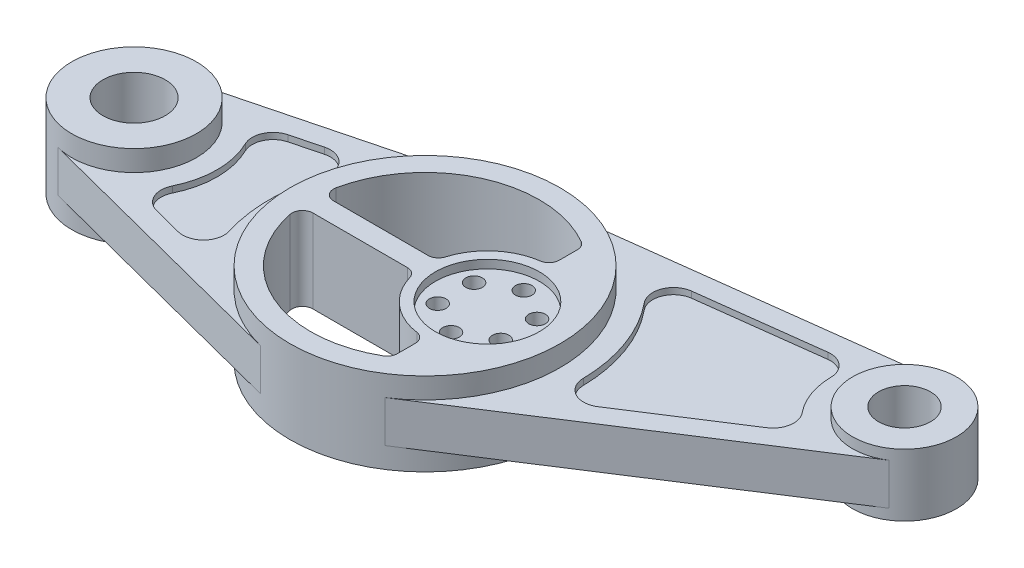
from build123d import *

# Parameters (mm, degrees)
BOSS_EXTRUDE1_DEPTH  = 10
SKETCH2_R            = 65
BOSS_EXTRUDE2_DEPTH  = 20
SKETCH3_R            = 30
BOSS_EXTRUDE3_DEPTH  = 20
SKETCH5_R            = 25
BOSS_EXTRUDE4_DEPTH  = 15
CUT_EXTRUDE1_DEPTH   = 41
SKETCH8_R            = 25
CUT_EXTRUDE3_DEPTH   = 4
SKETCH9_R            = 4
CUT_EXTRUDE4_DEPTH   = 37
CIRPATTERN1_COUNT    = 6
SKETCH10_R           = 15
CUT_EXTRUDE5_DEPTH   = 41
SKETCH11_R           = 12.5
CUT_EXTRUDE6_DEPTH   = 36
CUT_EXTRUDE7_DEPTH   = 3
FILLET1_R            = 10
FILLET1_OF_MIRROR3_R = 10


with BuildPart() as part:
    # Sketch1 → Boss-Extrude1 (new body, symmetric)
    with BuildSketch(Plane(origin=(0, 0, 0), x_dir=(1, 0, 0), z_dir=(0, 1, 0))):
        with BuildLine():
            Line((-147.5, 29.047375), (-16.25, 62.935979))
            ThreePointArc((-16.25, 62.935979), (-12.200915, 63.844637), (-8.102101, 64.493069))
            Line((-8.102101, 64.493069), (166.028479, 86.368652))
            ThreePointArc((166.028479, 86.368652), (192.636987, 70.114129), (182.701893, 40.558823))
            Line((182.701893, 40.558823), (35.248776, -54.612487))
            ThreePointArc((35.248776, -54.612487), (10.371042, -64.167293), (-16.25, -62.935979))
            Line((-16.25, -62.935979), (-147.5, -29.047375))
            ThreePointArc((-147.5, -29.047375), (-170, 0), (-147.5, 29.047375))
        make_face()
    extrude(amount=BOSS_EXTRUDE1_DEPTH, both=True)

    # Sketch2 → Boss-Extrude2 (add, symmetric)
    with BuildSketch(Plane(origin=(0, 0, 0), x_dir=(1, 0, 0), z_dir=(0, 1, 0))):
        with Locations(Location((0, 0, 0), (0, 0, 270))):  # turned: the seam where the file's is
            Circle(SKETCH2_R)
    extrude(amount=BOSS_EXTRUDE2_DEPTH, both=True)

    # Sketch3 → Boss-Extrude3 (add, symmetric)
    with BuildSketch(Plane(origin=(0, 0, 0), x_dir=(1, 0, 0), z_dir=(0, 1, 0))):
        with Locations(Location((-140, 0, 0), (0, 0, 270))):  # turned: the seam where the file's is
            Circle(SKETCH3_R)
    extrude(amount=BOSS_EXTRUDE3_DEPTH, both=True)

    # Sketch5 → Boss-Extrude4 (add, symmetric)
    with BuildSketch(Plane(origin=(0, 0, 0), x_dir=(1, 0, 0), z_dir=(0, 1, 0))):
        with Locations(Location((169.144672, 61.563626, 0), (0, 0, 270))):  # turned: the seam where the file's is
            Circle(SKETCH5_R)
    extrude(amount=BOSS_EXTRUDE4_DEPTH, both=True)

    # Sketch6 → Cut-Extrude1 (cut, through all)
    with BuildSketch(Plane(origin=(0, 20, 0), x_dir=(1, 0, 0), z_dir=(0, 1, 0))):
        with BuildLine():
            Line((-48.989795, 5), (-3.54102, 5))
            ThreePointArc((-3.54102, 5), (-0.552948, 5.991081), (1.250555, 8.571429))
            ThreePointArc((1.250555, 8.571429), (10.395071, 22.707857), (25.714286, 29.6923))
            ThreePointArc((25.714286, 29.6923), (28.779645, 31.367748), (30, 34.641016))
            Line((30, 34.641016), (30, 43.30127))
            ThreePointArc((30, 43.30127), (29.330127, 45.80127), (27.5, 47.631397))
            ThreePointArc((27.5, 47.631397), (-22.573362, 50.154196), (-53.888774, 11))
            ThreePointArc((-53.888774, 11), (-52.862778, 6.837722), (-48.989795, 5))
        make_face()
    cut_extrude1 = extrude(amount=-CUT_EXTRUDE1_DEPTH, mode=Mode.SUBTRACT)

    # Mirror1: Cut-Extrude1 across plane
    add(cut_extrude1.mirror(Plane.XY), mode=Mode.SUBTRACT)

    # Sketch8 → Cut-Extrude3 (cut)
    with BuildSketch(Plane(origin=(0, 20, 0), x_dir=(1, 0, 0), z_dir=(0, 1, 0))):
        with Locations(Location((30, 0, 0), (0, 0, 270))):  # turned: the seam where the file's is
            Circle(SKETCH8_R)
    cut_extrude3 = extrude(amount=-CUT_EXTRUDE3_DEPTH, mode=Mode.SUBTRACT)

    # Mirror2: Cut-Extrude3 across plane
    add(cut_extrude3.mirror(Plane.ZX), mode=Mode.SUBTRACT)

    # Sketch9 → Cut-Extrude4 (cut, through all)
    with BuildSketch(Plane(origin=(0, 16, 0), x_dir=(1, 0, 0), z_dir=(0, 1, 0))):
        with Locations(Location((30, 17.5, 0), (0, 0, 270))):  # turned: the seam where the file's is
            Circle(SKETCH9_R)
    cut_extrude4 = extrude(amount=-CUT_EXTRUDE4_DEPTH, mode=Mode.SUBTRACT)

    # CirPattern1: Cut-Extrude4 ×6 about axis
    cirpattern1_axis = Axis((30, 0, 0), (0, 1, 0))
    for i in range(1, CIRPATTERN1_COUNT):
        add(cut_extrude4.rotate(cirpattern1_axis, i * 360 / CIRPATTERN1_COUNT), mode=Mode.SUBTRACT)

    # Sketch10 → Cut-Extrude5 (cut, through all)
    with BuildSketch(Plane(origin=(0, 20, 0), x_dir=(1, 0, 0), z_dir=(0, 1, 0))):
        with Locations(Location((-140, 0, 0), (0, 0, 270))):  # turned: the seam where the file's is
            Circle(SKETCH10_R)
    extrude(amount=-CUT_EXTRUDE5_DEPTH, mode=Mode.SUBTRACT)

    # Sketch11 → Cut-Extrude6 (cut, through all)
    with BuildSketch(Plane(origin=(0, 15, 0), x_dir=(1, 0, 0), z_dir=(0, 1, 0))):
        with Locations(Location((169.144672, 61.563626, 0), (0, 0, 270))):  # turned: the seam where the file's is
            Circle(SKETCH11_R)
    extrude(amount=-CUT_EXTRUDE6_DEPTH, mode=Mode.SUBTRACT)

    # Sketch12 → Cut-Extrude7 (cut)
    with BuildSketch(Plane(origin=(0, 10, 0), x_dir=(1, 0, 0), z_dir=(0, 1, 0))):
        with BuildLine():
            Line((72.667447, -18.559151), (150.709797, 31.812064))
            ThreePointArc((150.709797, 31.812064), (136.25543, 49.592921), (135.898804, 72.504935))
            Line((135.898804, 72.504935), (43.736902, 60.926869))
            ThreePointArc((43.736902, 60.926869), (70.476947, 25.651511), (72.667447, -18.559151))
        make_face()
        with BuildLine():
            Line((-63.121044, 40.505972), (-111.45898, 28.025171))
            ThreePointArc((-111.45898, 28.025171), (-100, 0), (-111.45898, -28.025171))
            Line((-111.45898, -28.025171), (-63.121044, -40.505972))
            ThreePointArc((-63.121044, -40.505972), (-75, 0), (-63.121044, 40.505972))
        make_face()
    cut_extrude7 = extrude(amount=-CUT_EXTRUDE7_DEPTH, mode=Mode.SUBTRACT)

    # Fillet1
    fillet1_edges = [part.edges().sort_by_distance(p)[0] for p in [
        (-63.121044, 8.5, -40.505972),
        (-63.121044, 8.5, 40.505972),
        (-111.45898, 8.5, 28.025171),
        (-111.45898, 8.5, -28.025171),
        (72.667447, 8.5, 18.559151),
        (43.736902, 8.5, -60.926869),
        (135.898804, 8.5, -72.504935),
        (150.709797, 8.5, -31.812064),
    ]]
    fillet(fillet1_edges, radius=FILLET1_R)

    # Mirror3: Cut-Extrude7 across plane
    add(cut_extrude7.mirror(Plane.ZX), mode=Mode.SUBTRACT)

    # Fillet1 of Mirror3
    fillet1_of_mirror3_edges = [part.edges().sort_by_distance(p)[0] for p in [
        (-63.121044, -8.5, -40.505972),
        (-63.121044, -8.5, 40.505972),
        (-111.45898, -8.5, 28.025171),
        (-111.45898, -8.5, -28.025171),
        (72.667447, -8.5, 18.559151),
        (43.736902, -8.5, -60.926869),
        (135.898804, -8.5, -72.504935),
        (150.709797, -8.5, -31.812064),
    ]]
    fillet(fillet1_of_mirror3_edges, radius=FILLET1_OF_MIRROR3_R)


solid = part.part
